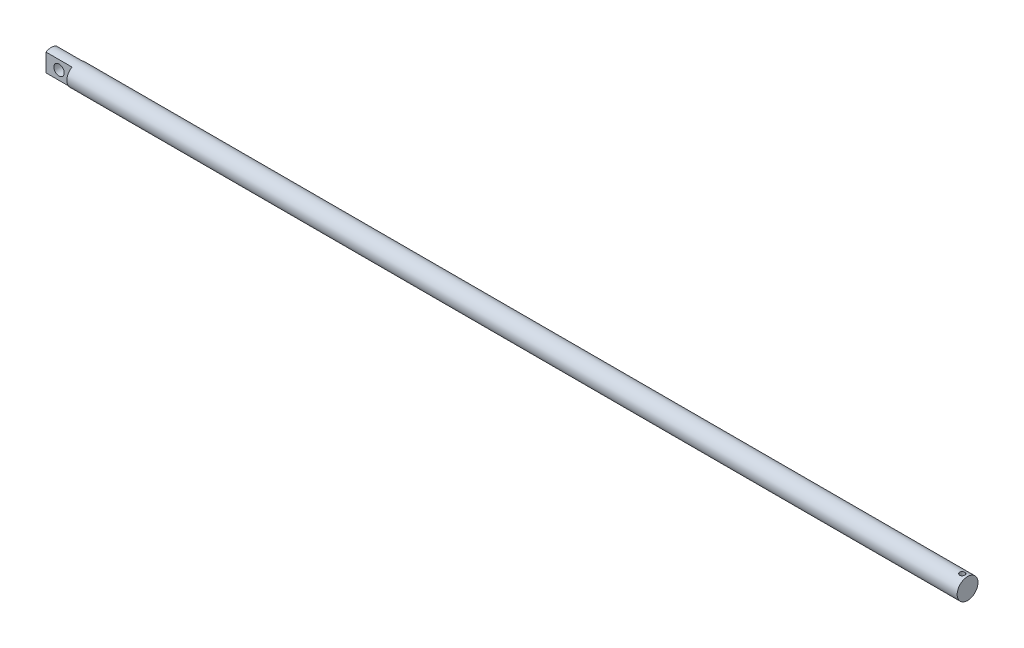
from build123d import *

# Parameters (mm, degrees)
SKETCH_1_R               = 8
EXTRUDE_1_DEPTH          = 703.5
SKETCH_2_R               = 4
CUT_EXTRUDE_1_DEPTH      = 9
CUT_EXTRUDE_1_DEPTH_BACK = 9
SKETCH_3_OUTSIDE_W       = 158.772
SKETCH_3_OUTSIDE_H       = 158.772
SKETCH_3_OUTSIDE_W_2     = 8
SKETCH_3_OUTSIDE_H_2     = 20
CUT_EXTRUDE_2_DEPTH      = 20
SKETCH_4_R               = 2
CUT_EXTRUDE_3_DEPTH      = 25


with BuildPart() as part:
    # 草图1 → 凸台-拉伸1 (new body)
    with BuildSketch(Plane(origin=(0, 0, 0), x_dir=(0, 0, -1), z_dir=(1, 0, 0))):
        Circle(SKETCH_1_R)
    extrude(amount=EXTRUDE_1_DEPTH)

    # 草图2 → 切除-拉伸1 (cut, two sides)
    with BuildSketch(Plane.XY) as cut_extrude_1_sk:
        with Locations((10, 0)):
            Circle(SKETCH_2_R)
    extrude(amount=CUT_EXTRUDE_1_DEPTH, mode=Mode.SUBTRACT)
    extrude(cut_extrude_1_sk.sketch, amount=-CUT_EXTRUDE_1_DEPTH_BACK, mode=Mode.SUBTRACT)

    # 草图3 outside → 切除-拉伸2 (cut)
    with BuildSketch(Plane.ZY):
        Rectangle(SKETCH_3_OUTSIDE_W, SKETCH_3_OUTSIDE_H)
        Rectangle(SKETCH_3_OUTSIDE_W_2, SKETCH_3_OUTSIDE_H_2, mode=Mode.SUBTRACT)
    extrude(amount=-CUT_EXTRUDE_2_DEPTH, mode=Mode.SUBTRACT)

    # 草图4 → 切除-拉伸3 (cut, symmetric)
    with BuildSketch(Plane(origin=(0, 0, 0), x_dir=(1, 0, 0), z_dir=(0, 1, 0))):
        with Locations((699.5, 0)):
            Circle(SKETCH_4_R)
    extrude(amount=CUT_EXTRUDE_3_DEPTH, both=True, mode=Mode.SUBTRACT)


solid = part.part
